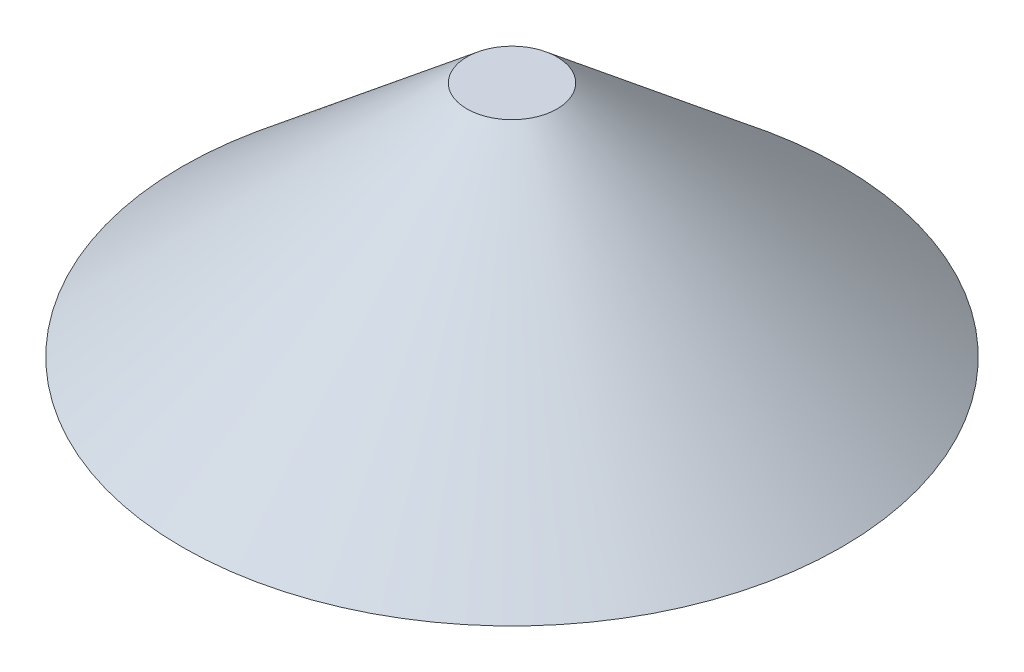
from build123d import *


with BuildPart() as part:
    # Sketch1 → Revolve1 (revolve)
    with BuildSketch(Plane.XY):
        Polygon((0, 0), (-69.5, 0), (-9.5, 50), (0, 50), align=None)
    revolve(axis=Axis((0, 50, 0), (0, -1, 0)))


solid = part.part
